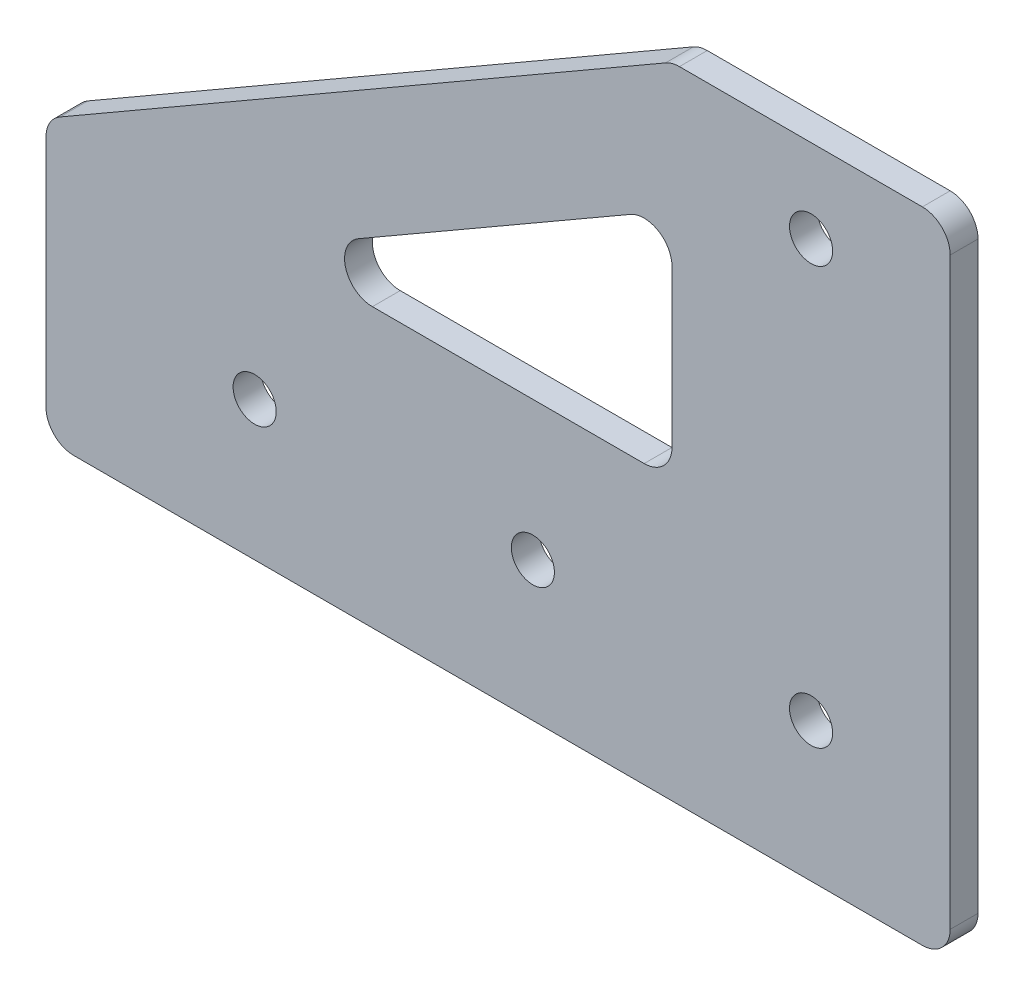
from build123d import *

# Parameters (mm, degrees)
EXTRUDE_1_DEPTH     = 2
SKETCH_2_R          = 1.55
CUT_EXTRUDE_1_DEPTH = 3
FILLET_1_R          = 2


with BuildPart() as part:
    # 草图1 → 凸台-拉伸1 (new body)
    with BuildSketch(Plane.XY):
        Polygon((-55, -180), (10, -180), (10, -134.019237886), (-10, -134.019237886), (-55, -160), align=None)
    extrude(amount=EXTRUDE_1_DEPTH)

    # 草图2 → 切除-拉伸1 (cut, through all)
    with BuildSketch(Plane(origin=(0, 0, 0), x_dir=(-1, 0, 0), z_dir=(0, 0, -1))):
        with Locations((40, -170)):
            Circle(SKETCH_2_R)
        with Locations((20, -170)):
            Circle(SKETCH_2_R)
        with Locations((0, -170)):
            Circle(SKETCH_2_R)
        with Locations((0, -140)):
            Circle(SKETCH_2_R)
        with BuildLine():
            Line((12, -160), (31.535898385, -160))
            ThreePointArc((31.535898385, -160), (33.467750037, -158.51763809), (32.535898385, -156.267949192))
            Line((32.535898385, -156.267949192), (13, -144.988893001))
            ThreePointArc((13, -144.988893001), (11, -144.988893001), (10, -146.720943809))
            Line((10, -146.720943809), (10, -158))
            ThreePointArc((10, -158), (10.585786438, -159.414213562), (12, -160))
        make_face()
    extrude(amount=-CUT_EXTRUDE_1_DEPTH, mode=Mode.SUBTRACT)

    # 圆角1
    fillet_1_edges = [part.edges().sort_by_distance(p)[0] for p in [
        (-55, -160, 1),
        (-10, -134.019237886, 1),
        (10, -134.019237886, 1),
        (10, -180, 1),
        (-55, -180, 1),
    ]]
    fillet(fillet_1_edges, radius=FILLET_1_R)


solid = part.part
